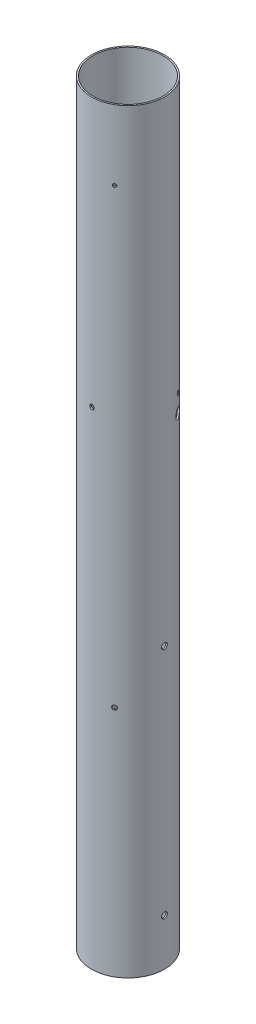
from build123d import *

# Parameters (mm, degrees)
SKETCH1_R           = 39.7891
SKETCH1_R_2         = 38.1635
BOSS_EXTRUDE1_DEPTH = 822.5282
CUT_EXTRUDE1_REACH  = 830.026
SKETCH2_R           = 1.778
CIRPATTERN1_COUNT   = 3
CUT_EXTRUDE2_REACH  = 829.326
SKETCH3_R           = 3.175
CUT_EXTRUDE3_REACH  = 830.016
SKETCH4_R           = 2.38125
CIRPATTERN2_COUNT   = 3
CUT_EXTRUDE4_REACH  = 830.036
SKETCH6_R           = 5.55625
CUT_EXTRUDE5_REACH  = 830.026
SKETCH7_R           = 2.38125
CIRPATTERN3_COUNT   = 3


with BuildPart() as part:
    # Sketch1 → Boss-Extrude1 (new body)
    with BuildSketch(Plane(origin=(0, 0, 0), x_dir=(1, 0, 0), z_dir=(0, 1, 0))):
        Circle(SKETCH1_R)
        Circle(SKETCH1_R_2, mode=Mode.SUBTRACT)
    extrude(amount=BOSS_EXTRUDE1_DEPTH)

    # Sketch2 → Cut-Extrude1 (cut, up to next)
    with BuildSketch(Plane(origin=(19.89455, 0, 34.458371394), x_dir=(0, -1, 0), z_dir=(0.499999999999998, 0, 0.8660254037844398)), mode=Mode.PRIVATE) as cut_extrude1_sk1:
        with Locations((-746.3282, 0)):
            Circle(SKETCH2_R)
    cut_extrude1_tool1 = extrude(cut_extrude1_sk1.sketch, amount=-CUT_EXTRUDE1_REACH, mode=Mode.PRIVATE) & part.part
    cut_extrude1 = cut_extrude1_tool1.solids().sort_by_distance((19.89455, 746.3282, 34.458371))[0]
    add(cut_extrude1, mode=Mode.SUBTRACT)

    # CirPattern1: Cut-Extrude1 ×3 about axis
    cirpattern1_axis = Axis((0, -40.64, 0), (0, 1, 0))
    for i in range(1, CIRPATTERN1_COUNT):
        add(cut_extrude1.rotate(cirpattern1_axis, i * 360 / CIRPATTERN1_COUNT), mode=Mode.SUBTRACT)

    # Sketch3 → Cut-Extrude2 (cut, up to next)
    with BuildSketch(Plane(origin=(39.7891, 0, 0), x_dir=(0, 0, -1), z_dir=(1, 0, 0)), mode=Mode.PRIVATE) as cut_extrude2_sk1:
        with Locations((0, 50.8)):
            Circle(SKETCH3_R)
    cut_extrude2_tool1 = extrude(cut_extrude2_sk1.sketch, amount=-CUT_EXTRUDE2_REACH, mode=Mode.PRIVATE) & part.part
    # Sketch3 → Cut-Extrude2 (cut, up to next)
    with BuildSketch(Plane(origin=(39.7891, 0, 0), x_dir=(0, 0, -1), z_dir=(1, 0, 0)), mode=Mode.PRIVATE) as cut_extrude2_sk2:
        with Locations((0, 304.8)):
            Circle(SKETCH3_R)
    cut_extrude2_tool2 = extrude(cut_extrude2_sk2.sketch, amount=-CUT_EXTRUDE2_REACH, mode=Mode.PRIVATE) & part.part
    add(cut_extrude2_tool1.solids().sort_by_distance((39.7891, 50.8, 0))[0], mode=Mode.SUBTRACT)
    add(cut_extrude2_tool2.solids().sort_by_distance((39.7891, 304.8, 0))[0], mode=Mode.SUBTRACT)

    # Sketch4 → Cut-Extrude3 (cut, up to next)
    with BuildSketch(Plane(origin=(-34.736171241, 0, -19.405434453), x_dir=(0, -1, 0), z_dir=(-0.8730072115474079, 0, -0.48770729806536567)), mode=Mode.PRIVATE) as cut_extrude3_sk1:
        with Locations((-530.4282, 0)):
            Circle(SKETCH4_R)
    cut_extrude3_tool1 = extrude(cut_extrude3_sk1.sketch, amount=-CUT_EXTRUDE3_REACH, mode=Mode.PRIVATE) & part.part
    cut_extrude3 = cut_extrude3_tool1.solids().sort_by_distance((-34.736171, 530.4282, -19.405434))[0]
    add(cut_extrude3, mode=Mode.SUBTRACT)

    # CirPattern2: Cut-Extrude3 ×3 about axis
    cirpattern2_axis = Axis((0, -40.64, 0), (0, 1, 0))
    for i in range(1, CIRPATTERN2_COUNT):
        add(cut_extrude3.rotate(cirpattern2_axis, i * 360 / CIRPATTERN2_COUNT), mode=Mode.SUBTRACT)

    # Sketch6 → Cut-Extrude4 (cut, up to next)
    with BuildSketch(Plane(origin=(34.173684829, 0, -20.379689498), x_dir=(0, -1, 0), z_dir=(0.8588705155093787, 0, -0.5121927738543899)), mode=Mode.PRIVATE) as cut_extrude4_sk1:
        with Locations((-511.3782, 0)):
            Circle(SKETCH6_R)
    cut_extrude4_tool1 = extrude(cut_extrude4_sk1.sketch, amount=-CUT_EXTRUDE4_REACH, mode=Mode.PRIVATE) & part.part
    add(cut_extrude4_tool1.solids().sort_by_distance((34.173685, 511.3782, -20.379689))[0], mode=Mode.SUBTRACT)

    # Sketch7 → Cut-Extrude5 (cut, up to next)
    with BuildSketch(Plane(origin=(19.89455, 0, 34.458371394), x_dir=(0, -1, 0), z_dir=(0.499999999999998, 0, 0.8660254037844398)), mode=Mode.PRIVATE) as cut_extrude5_sk1:
        with Locations((-254, 0)):
            Circle(SKETCH7_R)
    cut_extrude5_tool1 = extrude(cut_extrude5_sk1.sketch, amount=-CUT_EXTRUDE5_REACH, mode=Mode.PRIVATE) & part.part
    cut_extrude5 = cut_extrude5_tool1.solids().sort_by_distance((19.89455, 254, 34.458371))[0]
    add(cut_extrude5, mode=Mode.SUBTRACT)

    # CirPattern3: Cut-Extrude5 ×3 about axis
    cirpattern3_axis = Axis((0, -40.64, 0), (0, 1, 0))
    for i in range(1, CIRPATTERN3_COUNT):
        add(cut_extrude5.rotate(cirpattern3_axis, i * 360 / CIRPATTERN3_COUNT), mode=Mode.SUBTRACT)


solid = part.part
